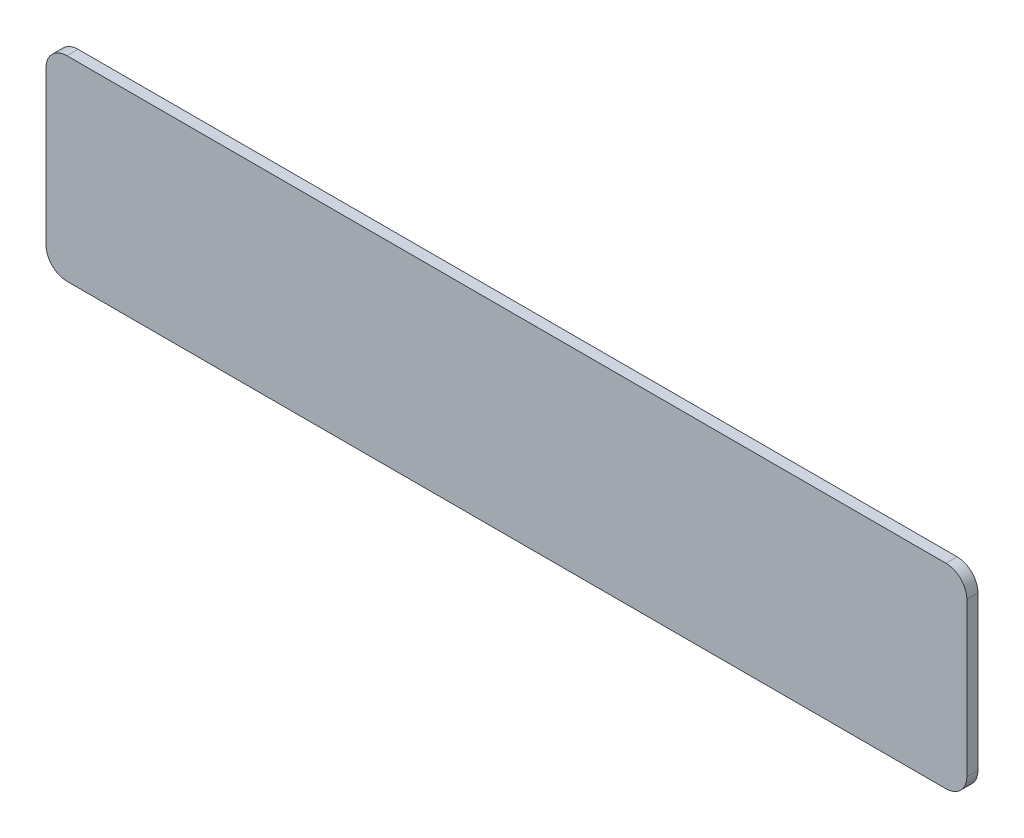
from build123d import *

# Parameters (mm, degrees)
BOSS_EXTRUDE1_DEPTH = 1.6


with BuildPart() as part:
    # Sketch1 → Boss-Extrude1 (new body)
    with BuildSketch(Plane.XY):
        with BuildLine():
            Line((3, 0), (129, 0))
            ThreePointArc((129, 0), (131.121320344, 0.878679656), (132, 3))
            Line((132, 3), (132, 25))
            ThreePointArc((132, 25), (131.121320344, 27.121320344), (129, 28))
            Line((129, 28), (3, 28))
            ThreePointArc((3, 28), (0.878679656, 27.121320344), (0, 25))
            Line((0, 25), (0, 3))
            ThreePointArc((0, 3), (0.878679656, 0.878679656), (3, 0))
        make_face()
    extrude(amount=BOSS_EXTRUDE1_DEPTH)


solid = part.part
